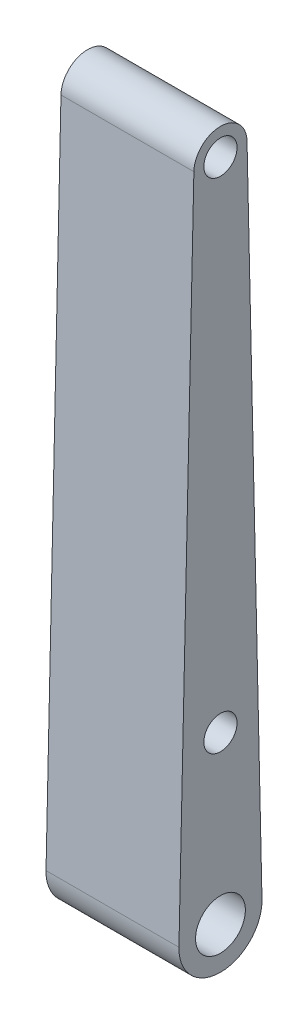
from build123d import *

# Parameters (mm, degrees)
SKETCH1_R           = 4.7625
BOSS_EXTRUDE1_DEPTH = 12.7
SKETCH2_R           = 3.175
CUT_EXTRUDE1_DEPTH  = 26.4


with BuildPart() as part:
    # Sketch1 → Boss-Extrude1 (new body, symmetric)
    with BuildSketch(Plane(origin=(0, 0, 0), x_dir=(0, 0, -1), z_dir=(1, 0, 0))):
        with BuildLine():
            Line((-5.078713962, 127.1143), (-7.935490566, 0.17859375))
            ThreePointArc((-7.935490566, 0.17859375), (0, -7.9375), (7.935490566, 0.17859375))
            Line((7.935490566, 0.17859375), (5.078713962, 127.1143))
            ThreePointArc((5.078713962, 127.1143), (0, 132.08), (-5.078713962, 127.1143))
        make_face()
        Circle(SKETCH1_R, mode=Mode.SUBTRACT)
    extrude(amount=BOSS_EXTRUDE1_DEPTH, both=True)

    # Sketch2 → Cut-Extrude1 (cut, through all)
    with BuildSketch(Plane(origin=(12.7, 0, 0), x_dir=(0, 0, -1), z_dir=(1, 0, 0))):
        with Locations((0, 31.75)):
            Circle(SKETCH2_R)
        with Locations((0, 127)):
            Circle(SKETCH2_R)
    extrude(amount=-CUT_EXTRUDE1_DEPTH, mode=Mode.SUBTRACT)


solid = part.part
